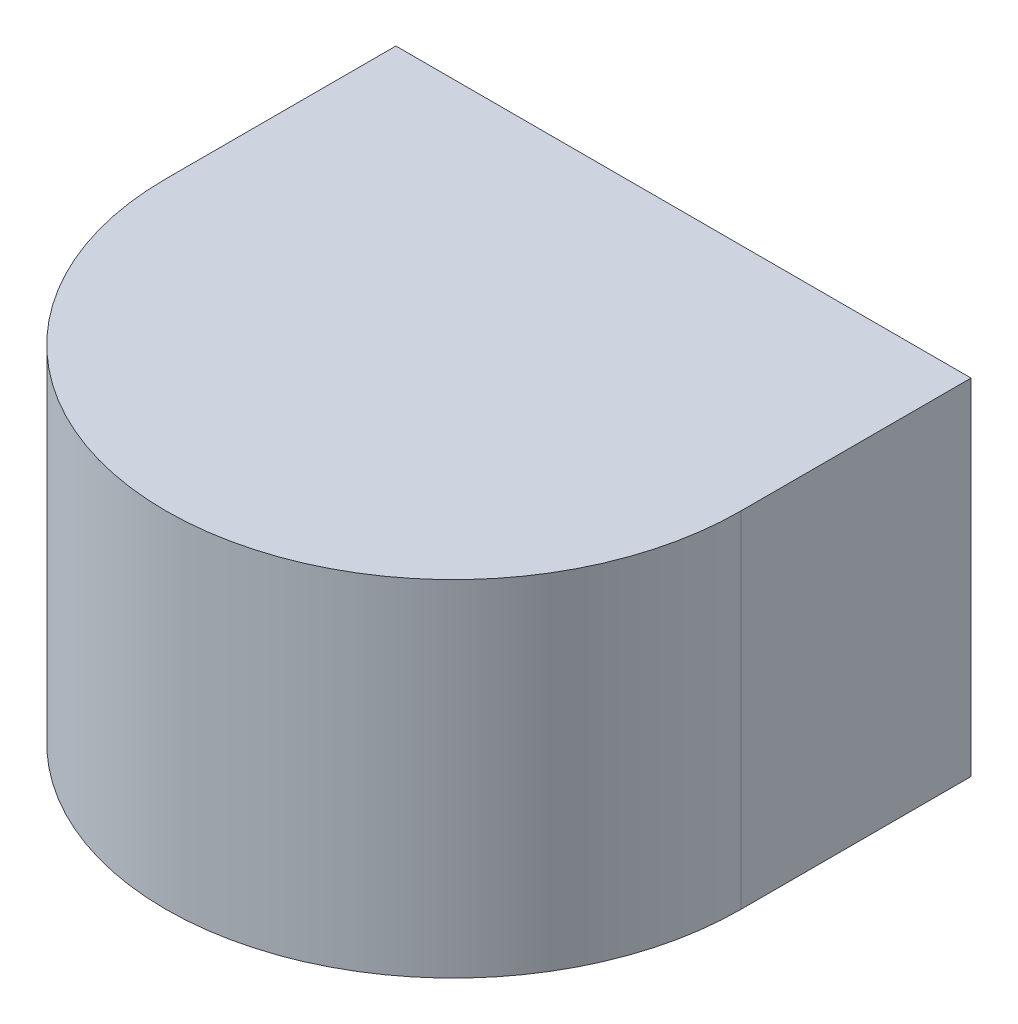
from build123d import *

# Parameters (mm, degrees)
BOSS_EXTRUDE1_DEPTH = 100
BOSS_EXTRUDE2_DEPTH = 50
SKETCH5_W           = 30
SKETCH5_H           = 45
CUT_EXTRUDE1_DEPTH  = 20


with BuildPart() as part:
    # Sketch3 → Boss-Extrude1 (new body)
    with BuildSketch(Plane(origin=(0, 0, 0), x_dir=(1, 0, 0), z_dir=(0, 1, 0))):
        with BuildLine():
            Line((-125, 0), (-125, 100))
            Line((-125, 100), (-100, 100))
            Line((-100, 100), (-100, 70))
            Line((-100, 70), (100, 70))
            Line((100, 70), (100, 100))
            Line((100, 100), (125, 100))
            Line((125, 100), (125, 0))
            ThreePointArc((125, 0), (0, -125), (-125, 0))
        make_face()
    extrude(amount=BOSS_EXTRUDE1_DEPTH)

    # Sketch4 → Boss-Extrude2 (add)
    with BuildSketch(Plane(origin=(0, 100, 0), x_dir=(1, 0, 0), z_dir=(0, 1, 0))):
        with BuildLine():
            Line((-100, 100), (100, 100))
            Line((100, 100), (125, 100))
            Line((125, 100), (125, 0))
            ThreePointArc((125, 0), (0, -125), (-125, 0))
            Line((-125, 0), (-125, 100))
            Line((-125, 100), (-100, 100))
        make_face()
    extrude(amount=BOSS_EXTRUDE2_DEPTH)

    # Sketch5 → Cut-Extrude1 (cut)
    with BuildSketch(Plane.XZ):
        with Locations((-98, 0)):
            Rectangle(SKETCH5_W, SKETCH5_H)
        with Locations((98, 0)):
            Rectangle(SKETCH5_W, SKETCH5_H)
    extrude(amount=-CUT_EXTRUDE1_DEPTH, mode=Mode.SUBTRACT)


solid = part.part
